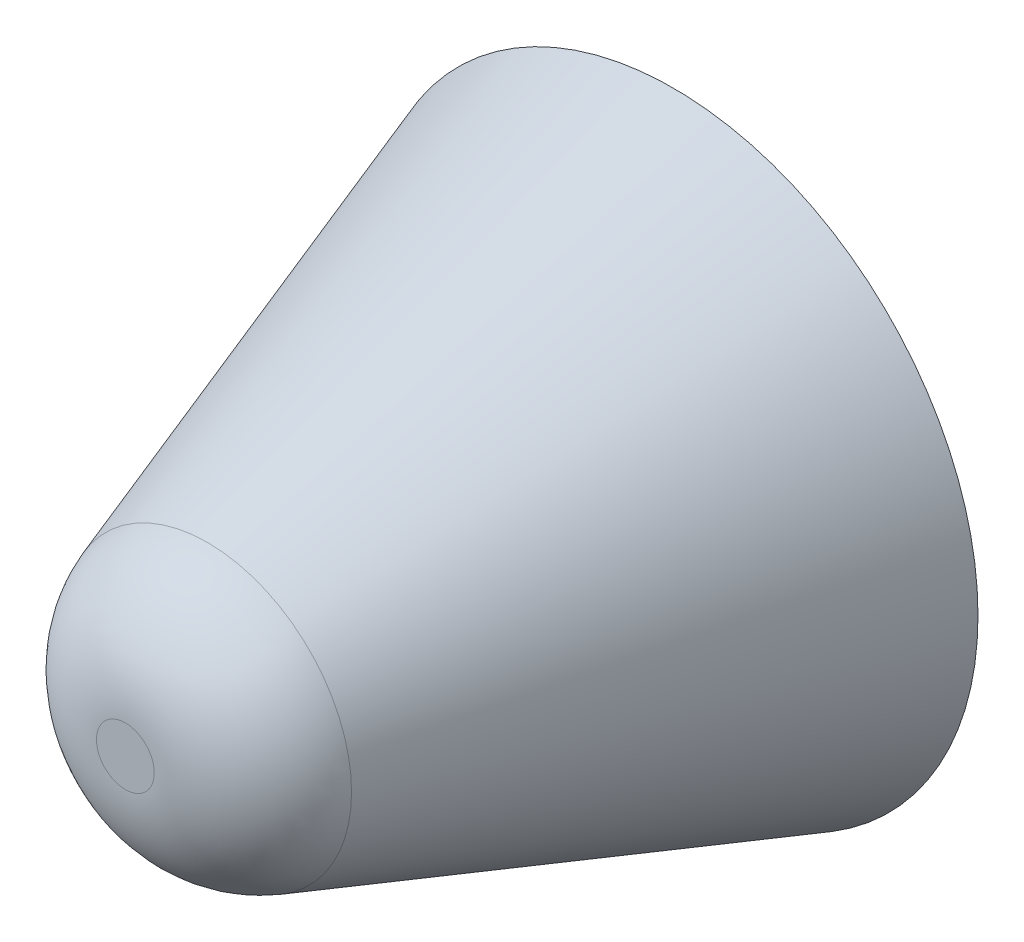
from build123d import *

# Parameters (mm, degrees)
SKETCH1_R           = 0.5
BOSS_EXTRUDE1_DEPTH = 0.9
BOSS_EXTRUDE1_TAPER = 19
FILLET1_R           = 0.2


with BuildPart() as part:
    # Sketch1 → Boss-Extrude1 (new body)
    with BuildSketch(Plane.XY):
        Circle(SKETCH1_R)
    extrude(amount=BOSS_EXTRUDE1_DEPTH, taper=BOSS_EXTRUDE1_TAPER)

    # Fillet1
    fillet1_edges = [part.edges().sort_by_distance(p)[0] for p in [
        (-0.190105148, 0, 0.9),
    ]]
    fillet(fillet1_edges, radius=FILLET1_R)


solid = part.part
